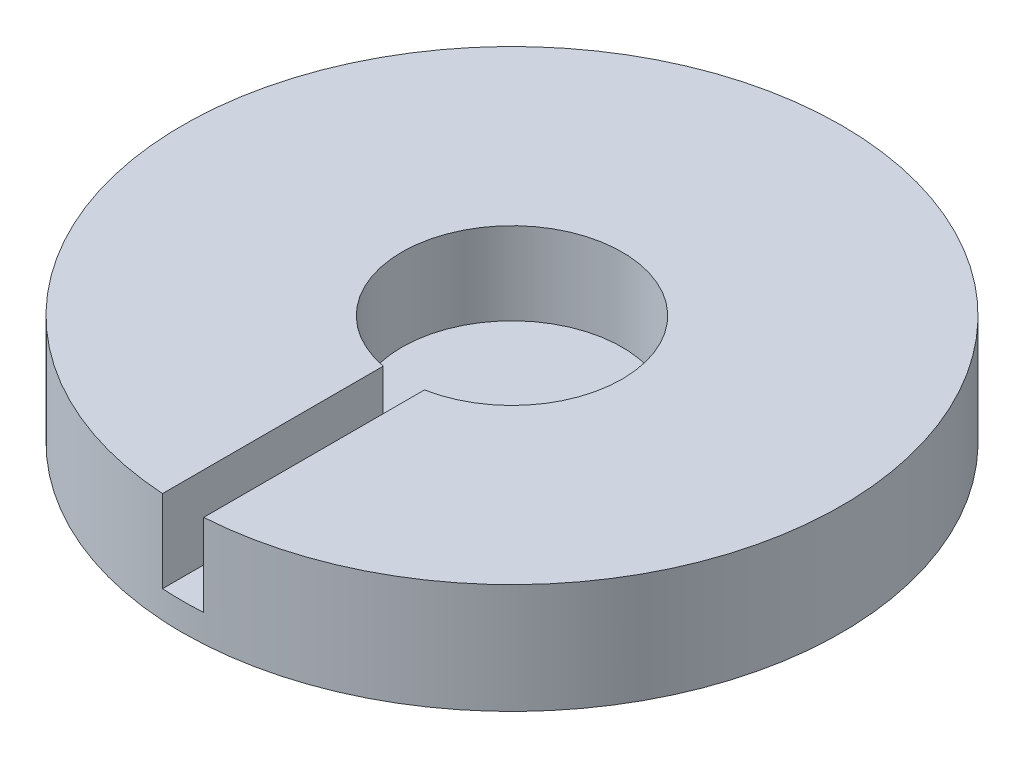
from build123d import *

# Parameters (mm, degrees)
SKETCH1_R           = 38.1
BOSS_EXTRUDE1_DEPTH = 12.7
CUT_EXTRUDE1_DEPTH  = 9.525


with BuildPart() as part:
    # Sketch1 → Boss-Extrude1 (new body)
    with BuildSketch(Plane(origin=(0, 0, 0), x_dir=(1, 0, 0), z_dir=(0, 1, 0))):
        Circle(SKETCH1_R)
    extrude(amount=BOSS_EXTRUDE1_DEPTH)

    # Sketch2 → Cut-Extrude1 (cut)
    with BuildSketch(Plane(origin=(0, 12.7, 0), x_dir=(1, 0, 0), z_dir=(0, 1, 0))):
        with BuildLine():
            Line((2.38125, -38.025513125), (2.38125, -12.507082254))
            ThreePointArc((2.38125, -12.507082254), (0, 12.73175), (-2.38125, -12.507082254))
            Line((-2.38125, -12.507082254), (-2.38125, -38.025513125))
            ThreePointArc((-2.38125, -38.025513125), (0, -38.1), (2.38125, -38.025513125))
        make_face()
    extrude(amount=-CUT_EXTRUDE1_DEPTH, mode=Mode.SUBTRACT)


solid = part.part
